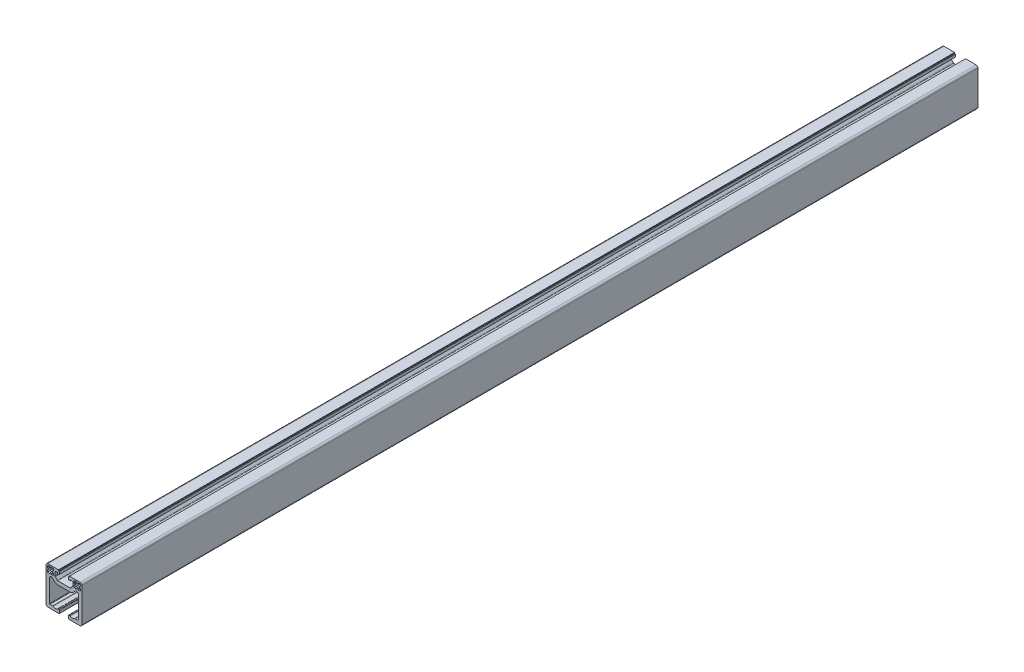
from build123d import *

# Parameters (mm, degrees)
EXTRUDE_1_DEPTH = 1000


with BuildPart() as part:
    # Model → 凸台-拉伸1 (new body)
    with BuildSketch(Plane.XY):
        with BuildLine():
            Line((1653.86794414, 609.935540563), (1656.86794414, 609.935540563))
            ThreePointArc((1656.86794414, 609.935540563), (1657.026058023, 609.909882212), (1657.16794414, 609.835540563))
            ThreePointArc((1657.16794414, 609.835540563), (1659.86794414, 608.935540563), (1662.56794414, 609.835540563))
            ThreePointArc((1662.56794414, 609.835540563), (1662.709830257, 609.909882212), (1662.86794414, 609.935540563))
            Line((1662.86794414, 609.935540563), (1663.86794414, 609.935540563))
            ThreePointArc((1663.86794414, 609.935540563), (1664.221497531, 609.789093954), (1664.36794414, 609.435540563))
            Line((1664.36794414, 609.435540563), (1664.36794414, 606.435540563))
            ThreePointArc((1664.36794414, 606.435540563), (1664.221497531, 606.081987172), (1663.86794414, 605.935540563))
            Line((1663.86794414, 605.935540563), (1651.36794414, 605.935540563))
            ThreePointArc((1651.36794414, 605.935540563), (1649.953730578, 606.521327001), (1649.36794414, 607.935540563))
            Line((1649.36794414, 607.935540563), (1649.36794414, 645.935540563))
            ThreePointArc((1649.36794414, 645.935540563), (1649.953730578, 647.349754125), (1651.36794414, 647.935540563))
            Line((1651.36794414, 647.935540563), (1663.26794414, 647.935540563))
            Line((1663.26794414, 647.935540563), (1663.26794414, 646.935540563))
            Line((1663.26794414, 646.935540563), (1664.26794414, 646.935540563))
            Line((1664.26794414, 646.935540563), (1664.26794414, 643.935540563))
            Line((1664.26794414, 643.935540563), (1662.26794414, 643.935540563))
            Line((1662.26794414, 643.935540563), (1662.26794414, 644.935540563))
            Line((1662.26794414, 644.935540563), (1660.36794414, 644.935540563))
            ThreePointArc((1660.36794414, 644.935540563), (1659.660837359, 644.642647344), (1659.36794414, 643.935540563))
            Line((1659.36794414, 643.935540563), (1659.36794414, 640.117521078))
            ThreePointArc((1659.36794414, 640.117521078), (1659.444064608, 639.734837646), (1659.660837359, 639.410414297))
            Line((1659.660837359, 639.410414297), (1661.842817874, 637.228433782))
            ThreePointArc((1661.842817874, 637.228433782), (1662.167241223, 637.011661031), (1662.549924656, 636.935540563))
            Line((1662.549924656, 636.935540563), (1676.185963625, 636.935540563))
            ThreePointArc((1676.185963625, 636.935540563), (1676.568647057, 637.011661031), (1676.893070406, 637.228433782))
            Line((1676.893070406, 637.228433782), (1679.075050921, 639.410414297))
            ThreePointArc((1679.075050921, 639.410414297), (1679.291823673, 639.734837646), (1679.36794414, 640.117521078))
            Line((1679.36794414, 640.117521078), (1679.36794414, 643.935540563))
            ThreePointArc((1679.36794414, 643.935540563), (1679.075050921, 644.642647344), (1678.36794414, 644.935540563))
            Line((1678.36794414, 644.935540563), (1676.46794414, 644.935540563))
            Line((1676.46794414, 644.935540563), (1676.46794414, 643.935540563))
            Line((1676.46794414, 643.935540563), (1674.46794414, 643.935540563))
            Line((1674.46794414, 643.935540563), (1674.46794414, 646.935540563))
            Line((1674.46794414, 646.935540563), (1675.46794414, 646.935540563))
            Line((1675.46794414, 646.935540563), (1675.46794414, 647.935540563))
            Line((1675.46794414, 647.935540563), (1687.36794414, 647.935540563))
            ThreePointArc((1687.36794414, 647.935540563), (1688.782157703, 647.349754125), (1689.36794414, 645.935540563))
            Line((1689.36794414, 645.935540563), (1689.36794414, 607.935540563))
            ThreePointArc((1689.36794414, 607.935540563), (1688.782157703, 606.521327001), (1687.36794414, 605.935540563))
            Line((1687.36794414, 605.935540563), (1674.86794414, 605.935540563))
            ThreePointArc((1674.86794414, 605.935540563), (1674.51439075, 606.081987172), (1674.36794414, 606.435540563))
            Line((1674.36794414, 606.435540563), (1674.36794414, 609.435540563))
            ThreePointArc((1674.36794414, 609.435540563), (1674.51439075, 609.789093954), (1674.86794414, 609.935540563))
            Line((1674.86794414, 609.935540563), (1675.86794414, 609.935540563))
            ThreePointArc((1675.86794414, 609.935540563), (1676.026058023, 609.909882212), (1676.16794414, 609.835540563))
            ThreePointArc((1676.16794414, 609.835540563), (1678.86794414, 608.935540563), (1681.56794414, 609.835540563))
            ThreePointArc((1681.56794414, 609.835540563), (1681.709830257, 609.909882212), (1681.86794414, 609.935540563))
            Line((1681.86794414, 609.935540563), (1684.86794414, 609.935540563))
            ThreePointArc((1684.86794414, 609.935540563), (1685.221497531, 610.081987172), (1685.36794414, 610.435540563))
            Line((1685.36794414, 610.435540563), (1685.36794414, 635.218026142))
            ThreePointArc((1685.36794414, 635.218026142), (1684.133311005, 637.065785207), (1681.953730578, 636.632239704))
            Line((1681.953730578, 636.632239704), (1679.721497531, 634.400006657))
            ThreePointArc((1679.721497531, 634.400006657), (1678.099380787, 633.3161429), (1676.185963625, 632.935540563))
            Line((1676.185963625, 632.935540563), (1662.549924656, 632.935540563))
            ThreePointArc((1662.549924656, 632.935540563), (1660.636507494, 633.3161429), (1659.01439075, 634.400006657))
            Line((1659.01439075, 634.400006657), (1656.782157703, 636.632239704))
            ThreePointArc((1656.782157703, 636.632239704), (1654.602577276, 637.065785207), (1653.36794414, 635.218026142))
            Line((1653.36794414, 635.218026142), (1653.36794414, 610.435540563))
            ThreePointArc((1653.36794414, 610.435540563), (1653.51439075, 610.081987172), (1653.86794414, 609.935540563))
        make_face()
        with BuildLine():
            Line((1657.86794414, 639.435540563), (1655.16794414, 639.435540563))
            Line((1655.16794414, 639.435540563), (1655.16794414, 640.435540563))
            Line((1655.16794414, 640.435540563), (1653.56794414, 640.435540563))
            Line((1653.56794414, 640.435540563), (1653.56794414, 639.435540563))
            Line((1653.56794414, 639.435540563), (1650.86794414, 639.435540563))
            Line((1650.86794414, 639.435540563), (1650.86794414, 642.135540563))
            Line((1650.86794414, 642.135540563), (1651.86794414, 642.135540563))
            Line((1651.86794414, 642.135540563), (1651.86794414, 643.735540563))
            Line((1651.86794414, 643.735540563), (1650.86794414, 643.735540563))
            Line((1650.86794414, 643.735540563), (1650.86794414, 645.435540563))
            ThreePointArc((1650.86794414, 645.435540563), (1651.160837359, 646.142647344), (1651.86794414, 646.435540563))
            Line((1651.86794414, 646.435540563), (1653.56794414, 646.435540563))
            Line((1653.56794414, 646.435540563), (1653.56794414, 645.435540563))
            Line((1653.56794414, 645.435540563), (1655.16794414, 645.435540563))
            Line((1655.16794414, 645.435540563), (1655.16794414, 646.435540563))
            Line((1655.16794414, 646.435540563), (1657.86794414, 646.435540563))
            Line((1657.86794414, 646.435540563), (1657.86794414, 643.735540563))
            Line((1657.86794414, 643.735540563), (1656.86794414, 643.735540563))
            Line((1656.86794414, 643.735540563), (1656.86794414, 642.135540563))
            Line((1656.86794414, 642.135540563), (1657.86794414, 642.135540563))
            Line((1657.86794414, 642.135540563), (1657.86794414, 639.435540563))
        make_face(mode=Mode.SUBTRACT)
        with BuildLine():
            Line((1686.86794414, 643.735540563), (1687.86794414, 643.735540563))
            Line((1687.86794414, 643.735540563), (1687.86794414, 645.435540563))
            ThreePointArc((1687.86794414, 645.435540563), (1687.575050921, 646.142647344), (1686.86794414, 646.435540563))
            Line((1686.86794414, 646.435540563), (1685.16794414, 646.435540563))
            Line((1685.16794414, 646.435540563), (1685.16794414, 645.435540563))
            Line((1685.16794414, 645.435540563), (1683.56794414, 645.435540563))
            Line((1683.56794414, 645.435540563), (1683.56794414, 646.435540563))
            Line((1683.56794414, 646.435540563), (1680.86794414, 646.435540563))
            Line((1680.86794414, 646.435540563), (1680.86794414, 643.735540563))
            Line((1680.86794414, 643.735540563), (1681.86794414, 643.735540563))
            Line((1681.86794414, 643.735540563), (1681.86794414, 642.135540563))
            Line((1681.86794414, 642.135540563), (1680.86794414, 642.135540563))
            Line((1680.86794414, 642.135540563), (1680.86794414, 639.435540563))
            Line((1680.86794414, 639.435540563), (1683.56794414, 639.435540563))
            Line((1683.56794414, 639.435540563), (1683.56794414, 640.435540563))
            Line((1683.56794414, 640.435540563), (1685.16794414, 640.435540563))
            Line((1685.16794414, 640.435540563), (1685.16794414, 639.435540563))
            Line((1685.16794414, 639.435540563), (1687.86794414, 639.435540563))
            Line((1687.86794414, 639.435540563), (1687.86794414, 642.135540563))
            Line((1687.86794414, 642.135540563), (1686.86794414, 642.135540563))
            Line((1686.86794414, 642.135540563), (1686.86794414, 643.735540563))
        make_face(mode=Mode.SUBTRACT)
    extrude(amount=EXTRUDE_1_DEPTH)


solid = part.part
